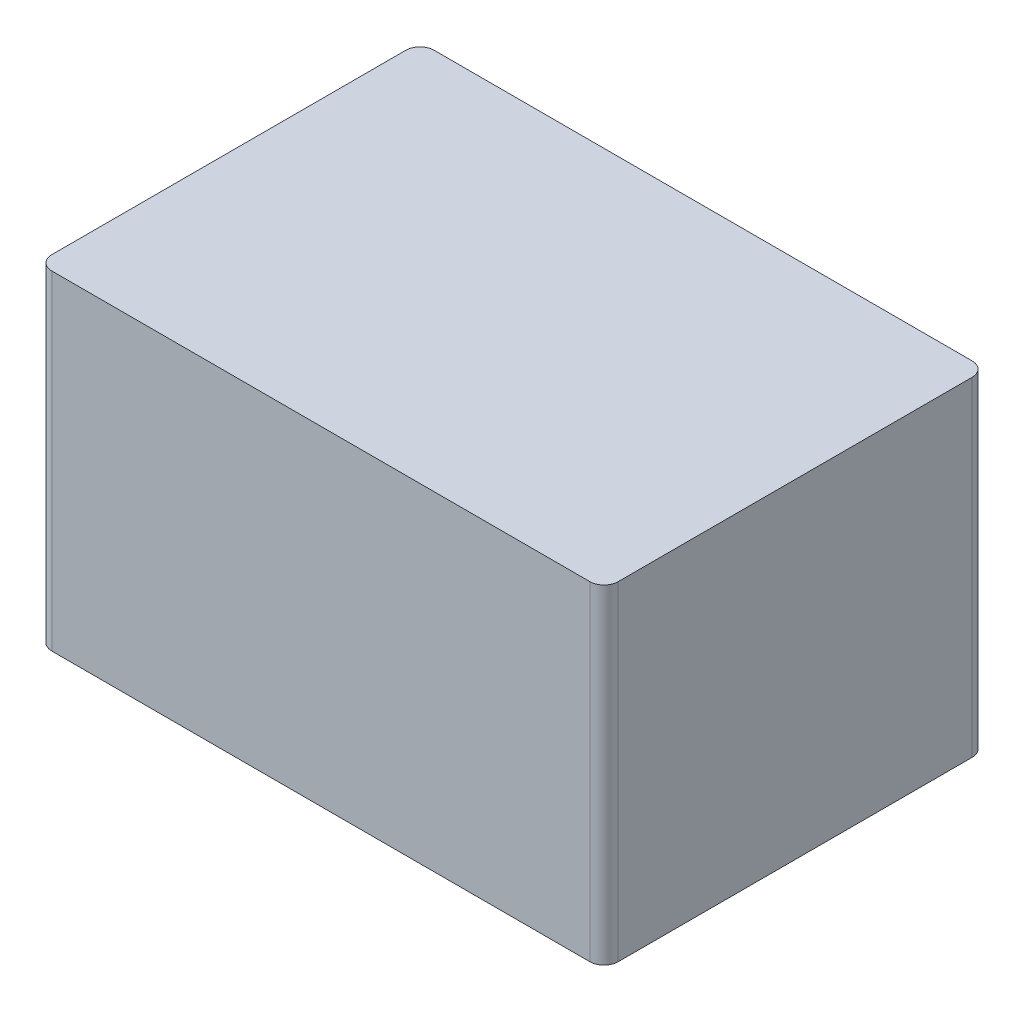
from build123d import *

# Parameters (mm, degrees)
SKETCH1_W           = 80
SKETCH1_H           = 54
BOSS_EXTRUDE2_DEPTH = 46.5
FILLET1_R           = 2


with BuildPart() as part:
    # Sketch1 → Boss-Extrude2 (new body)
    with BuildSketch(Plane(origin=(0, 0, 0), x_dir=(1, 0, 0), z_dir=(0, 1, 0))):
        with Locations((40, 27)):
            Rectangle(SKETCH1_W, SKETCH1_H)
    extrude(amount=BOSS_EXTRUDE2_DEPTH)

    # Fillet1
    fillet1_edges = [part.edges().sort_by_distance(p)[0] for p in [
        (0, 23.25, -54),
        (80, 23.25, -54),
        (80, 23.25, 0),
        (0, 23.25, 0),
    ]]
    fillet(fillet1_edges, radius=FILLET1_R)


solid = part.part
